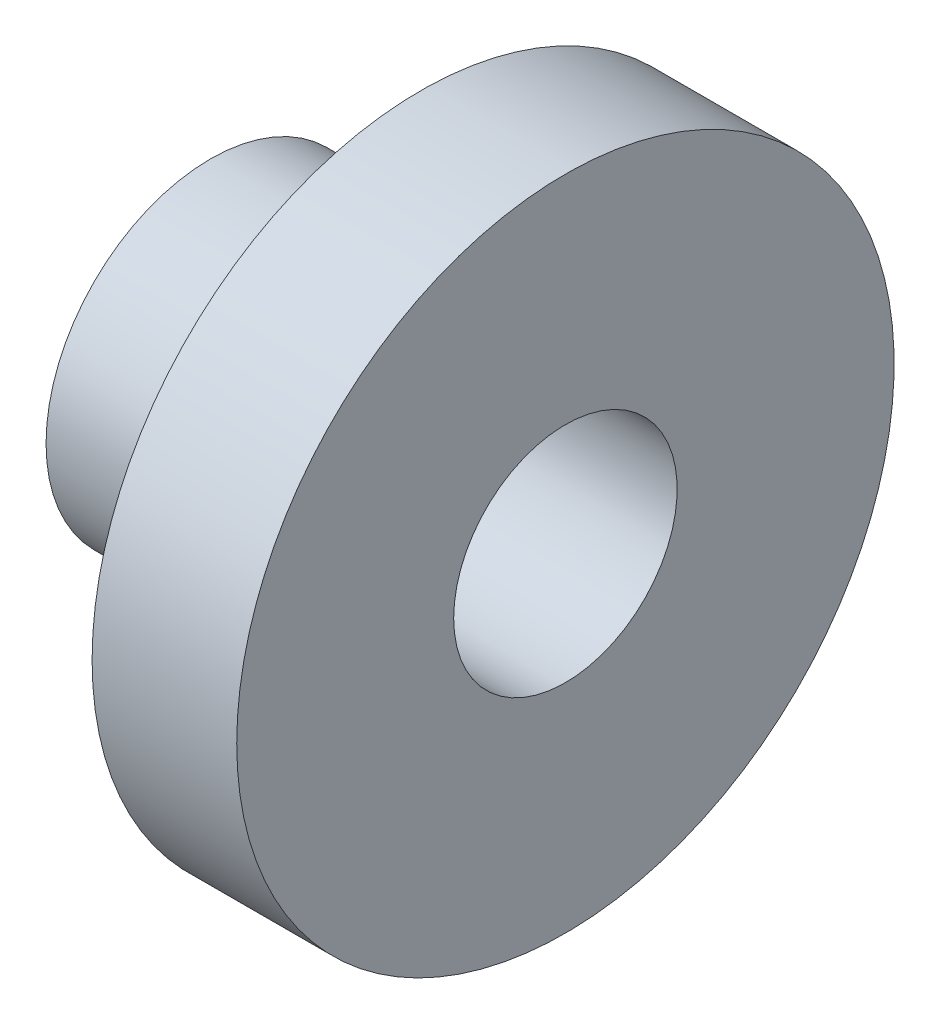
from build123d import *


with BuildPart() as part:
    # Sketch3 → Revolve1 (revolve)
    with BuildSketch(Plane.XY):
        Polygon((-13.5, 8.5), (13.5, 8.5), (13.5, 25), (2.5, 25), (2.5, 12.5), (-13.5, 12.5), align=None)
    revolve(axis=Axis((-13.5, 0, 0), (1, 0, 0)))


solid = part.part
